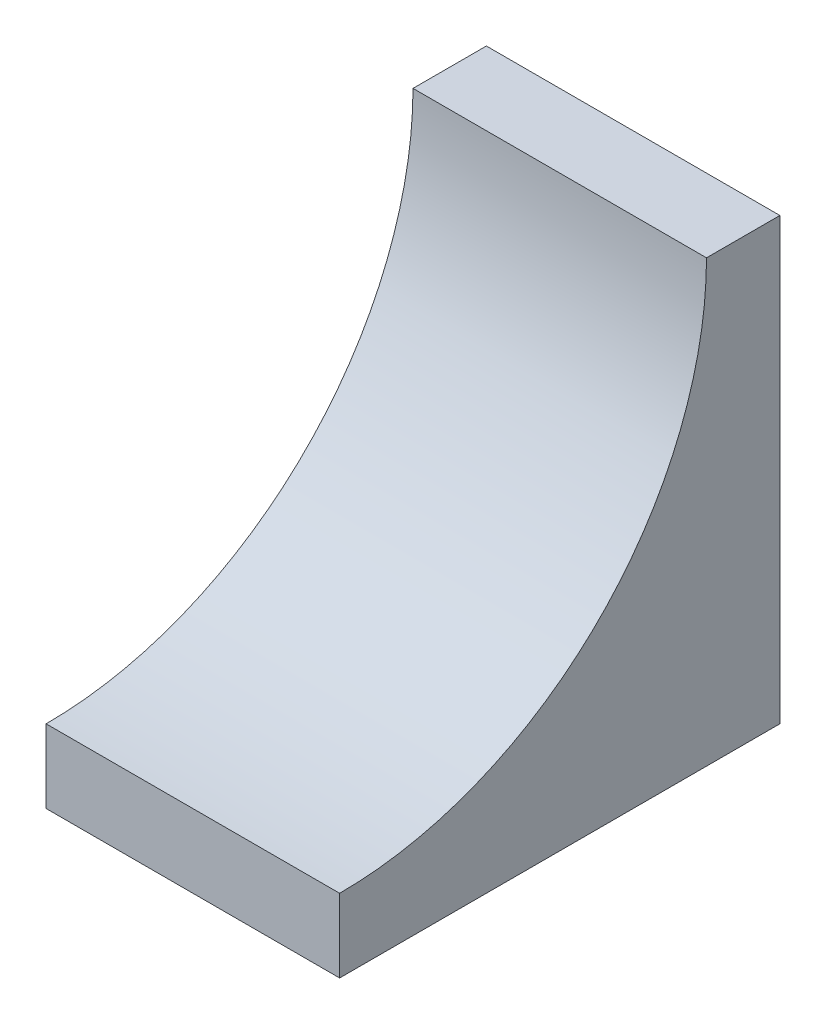
from build123d import *

# Parameters (mm, degrees)
BOSS_EXTRUDE1_DEPTH = 6.35


with BuildPart() as part:
    # Sketch1 → Boss-Extrude1 (new body, symmetric)
    with BuildSketch(Plane(origin=(0, 0, 0), x_dir=(0, 0, -1), z_dir=(1, 0, 0))):
        with BuildLine():
            Line((0, 19.05), (-3.175, 19.05))
            ThreePointArc((-3.175, 19.05), (-7.824679849, 7.824679849), (-19.05, 3.175))
            Line((-19.05, 3.175), (-19.05, 0))
            Line((-19.05, 0), (0, 0))
            Line((0, 0), (0, 19.05))
        make_face()
    extrude(amount=BOSS_EXTRUDE1_DEPTH, both=True)


solid = part.part
